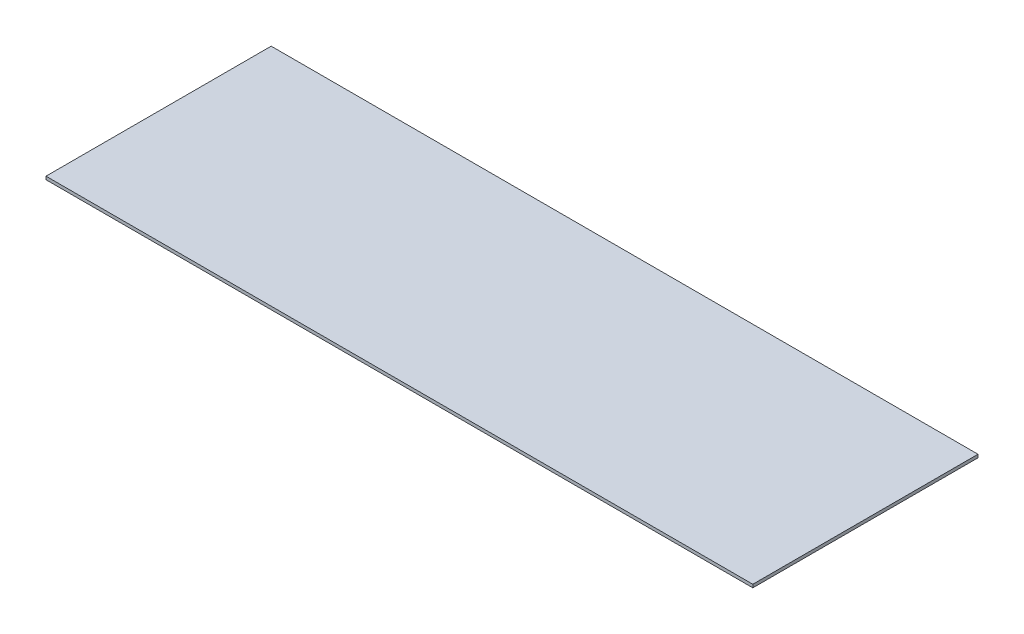
from build123d import *

# Parameters (mm, degrees)
SKETCH1_W           = 1130
SKETCH1_H           = 360
BOSS_EXTRUDE1_DEPTH = 5


with BuildPart() as part:
    # Sketch1 → Boss-Extrude1 (new body)
    with BuildSketch(Plane(origin=(0, 0, 0), x_dir=(1, 0, 0), z_dir=(0, 1, 0))):
        with Locations((-522.648714358, 151.739130435)):
            Rectangle(SKETCH1_W, SKETCH1_H)
    extrude(amount=BOSS_EXTRUDE1_DEPTH)


solid = part.part
